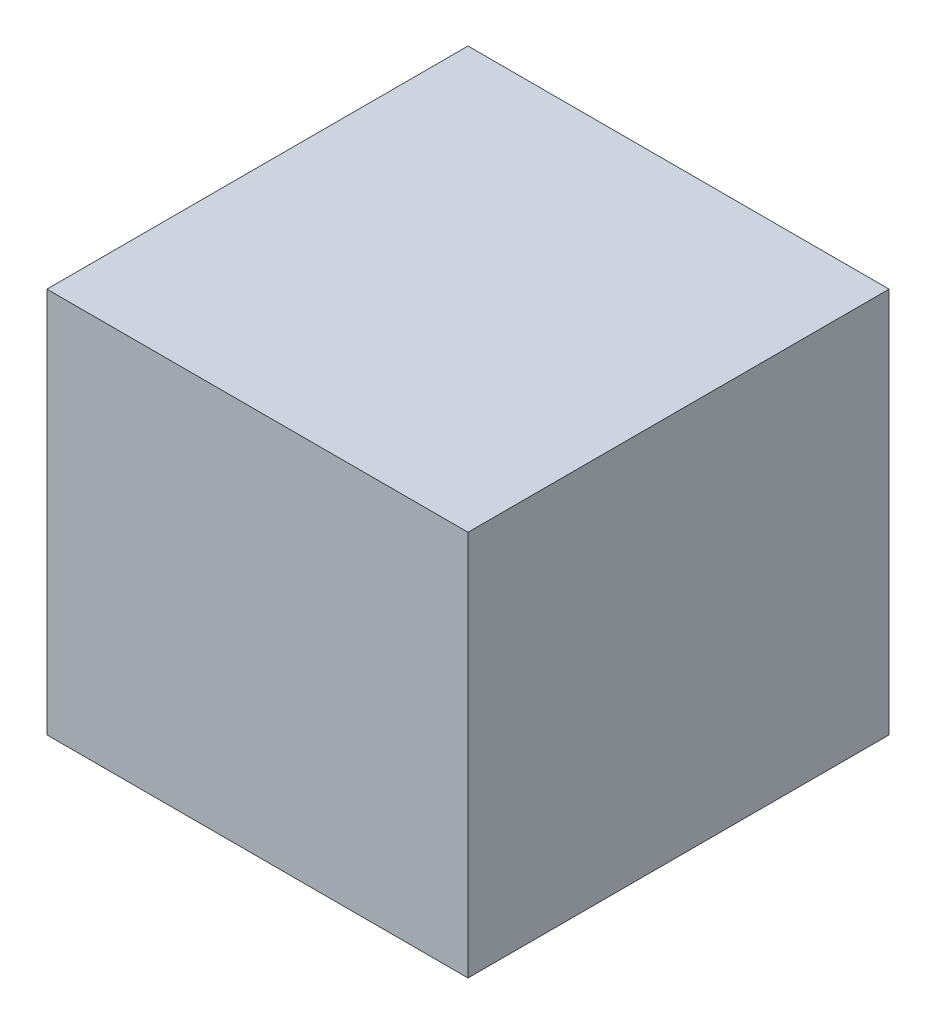
from build123d import *

# Parameters (mm, degrees)
SKETCH1_W           = 304.8
SKETCH1_H           = 279.4
BOSS_EXTRUDE1_DEPTH = 304.8


with BuildPart() as part:
    # Sketch1 → Boss-Extrude1 (new body)
    with BuildSketch(Plane.XY):
        with Locations((152.4, 139.7)):
            Rectangle(SKETCH1_W, SKETCH1_H)
    extrude(amount=BOSS_EXTRUDE1_DEPTH)


solid = part.part
